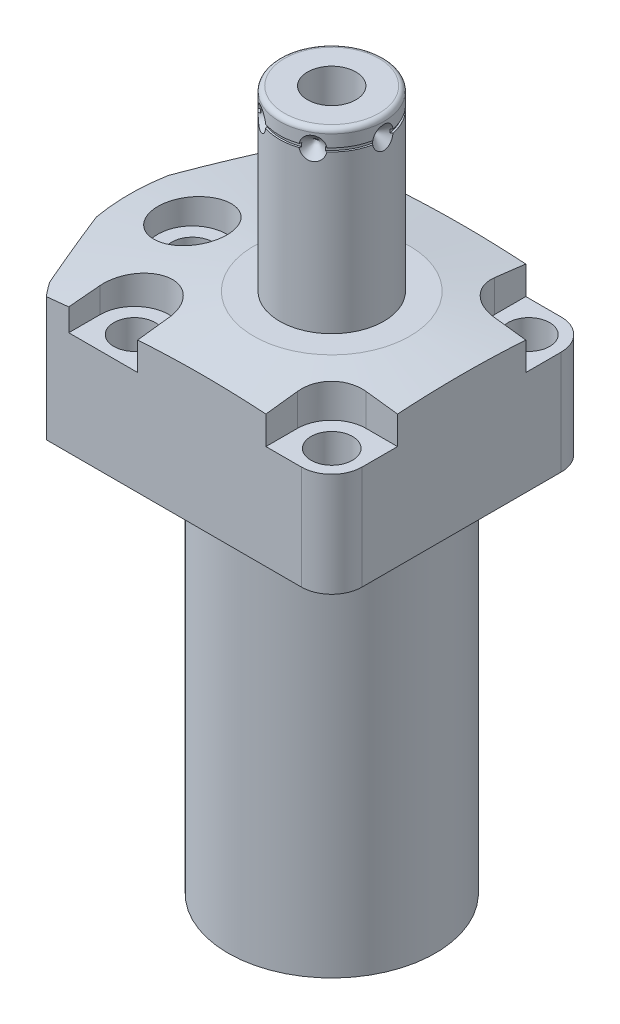
from build123d import *

# Parameters (mm, degrees)
CUT_EXTRUDE1_DEPTH       = 32.9946
CUT_EXTRUDE2_DEPTH       = 30.1498
CUT_EXTRUDE3_DEPTH       = 32.9946
FILLET1_R                = 6.477
CUT_EXTRUDE4_DEPTH       = 8.001
SKETCH11_R               = 2.7432
EXTRUDE1_DEPTH           = 2.9972
CUT_EXTRUDE5_DEPTH       = 1.27
CHAMFER1_SIZE            = 0.254
CHAMFER1_OF_MIRROR2_SIZE = 0.254
SKETCH16_R               = 1
SKETCH22_W               = 0.381
SKETCH22_H               = 0.762
HOLE1_AT_2_COUNT         = 2
HOLE1_AT_2_PITCH         = 54.877785999
HOLE1_AT_3_COUNT         = 2
HOLE1_AT_3_PITCH         = 54.877785999
HOLE1_AT_4_COUNT         = 2
HOLE1_AT_4_PITCH         = 22.73112685
HOLE1_AT_5_COUNT         = 2
HOLE1_AT_5_PITCH         = 22.73112685
SKETCH25_R               = 11.3665
CUT_EXTRUDE7_DEPTH       = 1.524
CIRPATTERN1_COUNT        = 6


with BuildPart() as part:
    # S2D0002 → Revolve1 (revolve)
    with BuildSketch(Plane.XY, mode=Mode.PRIVATE) as revolve1_sk:
        Polygon((-43.18, 0), (-43.18, 30.1498), (0, 30.1498), (0, -80.9752), (-22.098, -80.9752), (-22.098, 0), align=None)
    revolve(revolve1_sk.sketch.rotate(Axis((0, -3.4925, 0), (0, 1, 0)), 270), axis=Axis((0, -3.4925, 0), (0, 1, 0)))  # turned: the seam where the file's is

    # S2D0001 → Cut-Extrude1 (cut)
    with BuildSketch(Plane.XZ):
        with BuildLine():
            Line((-33.136049915, -27.686), (33.136049915, -27.686))
            ThreePointArc((33.136049915, -27.686), (0, -43.18), (-33.136049915, -27.686))
        make_face()
        with BuildLine():
            Line((33.136049915, 27.686), (-33.136049915, 27.686))
            ThreePointArc((-33.136049915, 27.686), (0, 43.18), (33.136049915, 27.686))
        make_face()
    extrude(amount=-CUT_EXTRUDE1_DEPTH, mode=Mode.SUBTRACT)

    # Sketch3 → Cut-Extrude2 (cut)
    with BuildSketch(Plane(origin=(0, 30.1498, 0), x_dir=(-1, 0, 0), z_dir=(0, -1, 0))):
        with BuildLine():
            Line((21.331674578, 58.746997027), (45.665477495, 0))
            Line((45.665477495, 0), (21.331674578, -58.746997027))
            ThreePointArc((21.331674578, -58.746997027), (62.5, 0), (21.331674578, 58.746997027))
        make_face()
    extrude(amount=CUT_EXTRUDE2_DEPTH, mode=Mode.SUBTRACT)

    # Sketch4 → Cut-Extrude3 (cut)
    with BuildSketch(Plane.XZ):
        with BuildLine():
            Line((27.686, -33.136049915), (27.686, 33.136049915))
            ThreePointArc((27.686, 33.136049915), (43.18, 0), (27.686, -33.136049915))
        make_face()
    extrude(amount=-CUT_EXTRUDE3_DEPTH, mode=Mode.SUBTRACT)

    # Fillet1
    fillet1_edges = [part.edges().sort_by_distance(p)[0] for p in [
        (27.686, 15.0749, 27.686),
        (27.686, 15.0749, -27.686),
    ]]
    fillet(fillet1_edges, radius=FILLET1_R)

    # Sketch5 → Cut-Extrude4 (cut)
    with BuildSketch(Plane(origin=(0, 30.1498, 0), x_dir=(-1, 0, 0), z_dir=(0, 1, 0))):
        with BuildLine():
            Line((-27.686, -13.6652), (-27.686, -27.686))
            Line((-27.686, -27.686), (-13.6652, -27.686))
            Line((-13.6652, -27.686), (-13.6652, -21.0058))
            ThreePointArc((-13.6652, -21.0058), (-15.815211962, -15.815211962), (-21.0058, -13.6652))
            Line((-21.0058, -13.6652), (-27.686, -13.6652))
        make_face()
        with BuildLine():
            Line((-13.6652, 21.0058), (-13.6652, 27.686))
            Line((-13.6652, 27.686), (-27.686, 27.686))
            Line((-27.686, 27.686), (-27.686, 13.6652))
            Line((-27.686, 13.6652), (-21.0058, 13.6652))
            ThreePointArc((-21.0058, 13.6652), (-15.815211962, 15.815211962), (-13.6652, 21.0058))
        make_face()
        with BuildLine():
            Line((13.6652, 27.686), (28.3464, 27.686))
            Line((28.3464, 27.686), (28.3464, 21.0058))
            ThreePointArc((28.3464, 21.0058), (21.0058, 13.6652), (13.6652, 21.0058))
            Line((13.6652, 21.0058), (13.6652, 27.686))
        make_face()
        with BuildLine():
            Line((13.6652, -27.686), (13.6652, -21.0058))
            ThreePointArc((13.6652, -21.0058), (21.0058, -13.6652), (28.3464, -21.0058))
            Line((28.3464, -21.0058), (28.3464, -27.686))
            Line((28.3464, -27.686), (13.6652, -27.686))
        make_face()
    extrude(amount=-CUT_EXTRUDE4_DEPTH, mode=Mode.SUBTRACT)

    # S2D0003 → Cut-Revolve1 (revolve, cut)
    with BuildSketch(Plane.XY, mode=Mode.PRIVATE) as cut_revolve1_sk:
        Polygon((-16.637, 30.1498), (-86.637, 20.311941571), (-86.637, 30.1498), align=None)
    revolve(cut_revolve1_sk.sketch.rotate(Axis((0, 12.958028823, 0), (0, 1, 0)), 270), axis=Axis((0, 12.958028823, 0), (0, 1, 0)), mode=Mode.SUBTRACT)  # turned: the seam where the file's is

    # Sketch7 → Cut-Revolve2 (revolve, cut)
    with BuildSketch(Plane.XZ.offset(-14.5034)):
        Polygon((-41.173297543, -10.181347778), (-42.857104646, -6.116277835), (-43.091770047, -6.213479427), (-38.977923149, -16.145184401), (-25.648928357, -10.624133986), (-27.923445606, -5.132963597), (-40.549917486, -10.363019494), (-41.04563442, -10.157686817), align=None)
    cut_revolve2 = revolve(axis=Axis((0, 14.5034, 0), (0.923879533, 0, 0.382683432)), mode=Mode.SUBTRACT)

    # Sketch9 → Cut-Revolve4 (revolve, cut)
    with BuildSketch(Plane.XY.offset(-11.8364), mode=Mode.PRIVATE) as cut_revolve4_sk:
        Polygon((-31.8262, 1.5), (-33.575, 1.5), (-33.575, 0), (-28.575, 0), (-28.575, 12.0664), (-29.8196, 12.0664), (-29.8196, 4.4972), (-31.8262, 4.4972), align=None)
    cut_revolve4 = revolve(cut_revolve4_sk.sketch.rotate(Axis((-28.575, -17.893386483, -11.8364), (0, 1, 0)), 180), axis=Axis((-28.575, -17.893386483, -11.8364), (0, 1, 0)), mode=Mode.SUBTRACT)  # turned: the seam where the file's is

    # Sketch11 → Extrude1 (add)
    with BuildSketch(Plane.XZ.offset(-4.4972)):
        with Locations(Location((-28.575, -11.8364, 0), (0, 0, 270))):  # turned: the seam where the file's is
            Circle(SKETCH11_R)
    extrude1 = extrude(amount=EXTRUDE1_DEPTH)

    # Sketch12 → Cut-Extrude5 (cut)
    with BuildSketch(Plane.XZ.offset(-1.5)):
        Polygon((-27.3304, -12.554970145), (-27.3304, -11.117829855), (-28.575, -10.39925971), (-29.8196, -11.117829855), (-29.8196, -12.554970145), (-28.575, -13.27354029), align=None)
    cut_extrude5 = extrude(amount=-CUT_EXTRUDE5_DEPTH, mode=Mode.SUBTRACT)

    # Chamfer1
    chamfer1_edges = [part.edges().sort_by_distance(p)[0] for p in [
        (-28.575, 1.5, -9.0932),
    ]]
    chamfer(chamfer1_edges, length=CHAMFER1_SIZE)

    # Mirror2: Cut-Revolve2, Cut-Revolve4, Extrude1, Cut-Extrude5 across plane
    add(cut_revolve2.mirror(Plane.XY), mode=Mode.SUBTRACT)
    add(cut_revolve4.mirror(Plane.XY), mode=Mode.SUBTRACT)
    add(extrude1.mirror(Plane.XY))
    add(cut_extrude5.mirror(Plane.XY), mode=Mode.SUBTRACT)

    # Chamfer1 of Mirror2
    chamfer1_of_mirror2_edges = [part.edges().sort_by_distance(p)[0] for p in [
        (-28.575, 1.5, 9.0932),
    ]]
    chamfer(chamfer1_of_mirror2_edges, length=CHAMFER1_OF_MIRROR2_SIZE)

    # Sketch17 → Revolve4 (revolve)
    with BuildSketch(Plane(origin=(0, 0, 0), x_dir=(0, 0, -1), z_dir=(1, 0, 0)), mode=Mode.PRIVATE) as revolve4_sk:
        with BuildLine():
            Line((0, 30.1498), (-11.1125, 30.1498))
            Line((-11.1125, 30.1498), (-11.1125, 67.018))
            ThreePointArc((-11.1125, 67.018), (-10.81492049, 67.73642049), (-10.0965, 68.034))
            Line((-10.0965, 68.034), (0, 68.034))
            Line((0, 68.034), (0, 30.1498))
        make_face()
    revolve(revolve4_sk.sketch.rotate(Axis((0, 24.99613, 0), (0, 1, 0)), 180), axis=Axis((0, 24.99613, 0), (0, 1, 0)))  # turned: the seam where the file's is

    # Sketch18 → Cut-Revolve7 (revolve, cut)
    with BuildSketch(Plane.XY, mode=Mode.PRIVATE) as cut_revolve7_sk:
        Polygon((5.1562, 68.034), (5.1562, 51.016), (0, 47.917842476), (0, 68.034), align=None)
    revolve(cut_revolve7_sk.sketch.rotate(Axis((0, -20.475979697, 0), (0, 1, 0)), 90), axis=Axis((0, -20.475979697, 0), (0, 1, 0)), mode=Mode.SUBTRACT)  # turned: the seam where the file's is

    # Sketch20 → Cut-Revolve8 (revolve, cut)
    with BuildSketch(Plane.XY, mode=Mode.PRIVATE) as cut_revolve8_sk:
        Polygon((-11.1125, 61.6586), (-11.1125, 64.0716), (-8.6995, 64.0716), align=None)
    cut_revolve8 = revolve(cut_revolve8_sk.sketch.rotate(Axis((0, 64.0716, 0), (1, 0, 0)), 270), axis=Axis((0, 64.0716, 0), (1, 0, 0)), mode=Mode.SUBTRACT)  # turned: the seam where the file's is

    # Sketch22 → Cut-Revolve6 (revolve, cut)
    with BuildSketch(Plane(origin=(0, 0, 0), x_dir=(0, 0, -1), z_dir=(1, 0, 0))):
        with Locations((10.922, 64.072)):
            Rectangle(SKETCH22_W, SKETCH22_H)
    revolve(axis=Axis((0, 41.8979, 0), (0, 1, 0)), mode=Mode.SUBTRACT)

    # Sketch23 → Hole1 (revolve, cut)
    with BuildSketch(Plane(origin=(-29.6926, 30.1498, 0), x_dir=(0, 0, 1), z_dir=(1, 0, 0))):
        Polygon((0, 0), (0, 30.1498), (4.4196, 30.1498), (4.4196, 8.001), (7.3406, 8.001), (7.3406, 0), align=None)
    hole1 = revolve(axis=Axis((-29.6926, -79.8502, 0), (0, 1, 0)), mode=Mode.SUBTRACT)

    # Hole1 at 2: Hole1 ×2
    with Locations(*[Vector(0.923841935, 0, 0.382774188) * (i * HOLE1_AT_2_PITCH) for i in range(1, HOLE1_AT_2_COUNT)]):
        add(hole1, mode=Mode.SUBTRACT)

    # Hole1 at 3: Hole1 ×2
    with Locations(*[Vector(0.923841935, 0, -0.382774188) * (i * HOLE1_AT_3_PITCH) for i in range(1, HOLE1_AT_3_COUNT)]):
        add(hole1, mode=Mode.SUBTRACT)

    # Hole1 at 4: Hole1 ×2
    with Locations(*[Vector(0.382154394, 0, 0.92409849) * (i * HOLE1_AT_4_PITCH) for i in range(1, HOLE1_AT_4_COUNT)]):
        add(hole1, mode=Mode.SUBTRACT)

    # Hole1 at 5: Hole1 ×2
    with Locations(*[Vector(0.382154394, 0, -0.92409849) * (i * HOLE1_AT_5_PITCH) for i in range(1, HOLE1_AT_5_COUNT)]):
        add(hole1, mode=Mode.SUBTRACT)

    # Sketch25 → Cut-Extrude7 (cut)
    with BuildSketch(Plane.XZ.offset(80.9752)):
        with Locations(Location((0, 0, 0), (0, 0, 270))):  # turned: the seam where the file's is
            Circle(SKETCH25_R)
    extrude(amount=-CUT_EXTRUDE7_DEPTH, mode=Mode.SUBTRACT)

    # CirPattern1: Cut-Revolve8 ×6 about axis
    cirpattern1_axis = Axis((0, -3.4925, 0), (0, 1, 0))
    for i in range(1, CIRPATTERN1_COUNT):
        add(cut_revolve8.rotate(cirpattern1_axis, i * 360 / CIRPATTERN1_COUNT), mode=Mode.SUBTRACT)


with BuildPart() as body_2:
    # Sketch16 → Revolve3 (revolve)
    with BuildSketch(Plane(origin=(-18.1864, 0, -11.8364), x_dir=(-1, 0, 0), z_dir=(0, 0, -1)), mode=Mode.PRIVATE) as revolve3_sk:
        with Locations((14.3886, 0.5)):
            Circle(SKETCH16_R)
    revolve(revolve3_sk.sketch.rotate(Axis((-28.575, -0.4101, -11.8364), (0, 1, 0)), 180), axis=Axis((-28.575, -0.4101, -11.8364), (0, 1, 0)))  # turned: the seam where the file's is


with BuildPart() as body_3:
    # Mirror3: mirrored copy
    add(body_2.part.mirror(Plane.XY))


solid = Compound([part.part, body_2.part, body_3.part])
